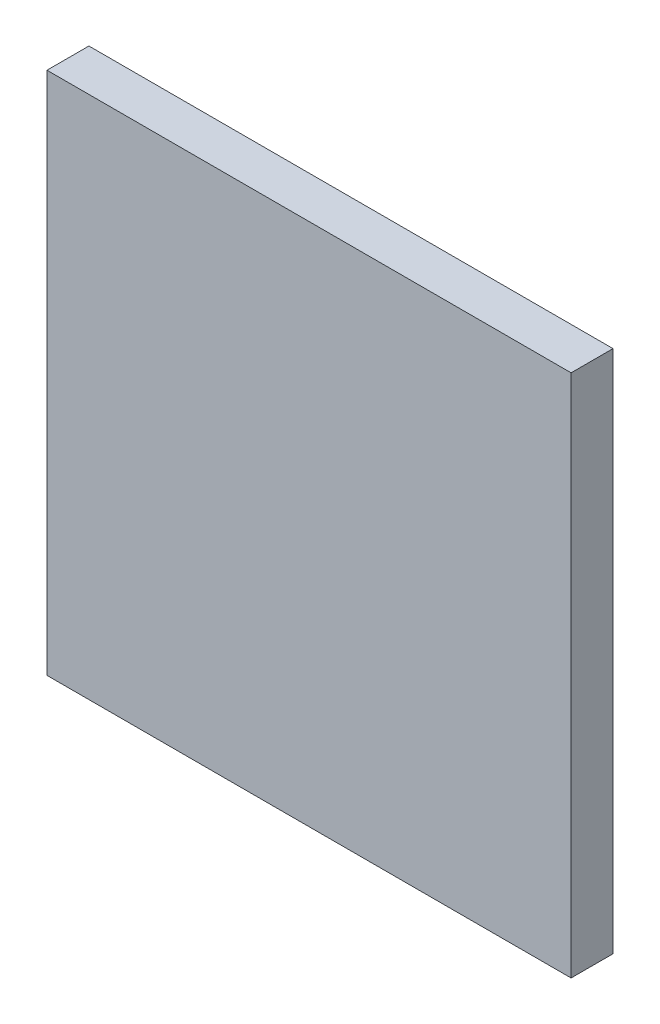
from build123d import *

# Parameters (mm, degrees)
SKETCH1_W           = 25
SKETCH1_H           = 25
BOSS_EXTRUDE1_DEPTH = 2


with BuildPart() as part:
    # Sketch1 → Boss-Extrude1 (new body)
    with BuildSketch(Plane.XY):
        with Locations((12.5, 12.5)):
            Rectangle(SKETCH1_W, SKETCH1_H)
    extrude(amount=BOSS_EXTRUDE1_DEPTH)


solid = part.part
